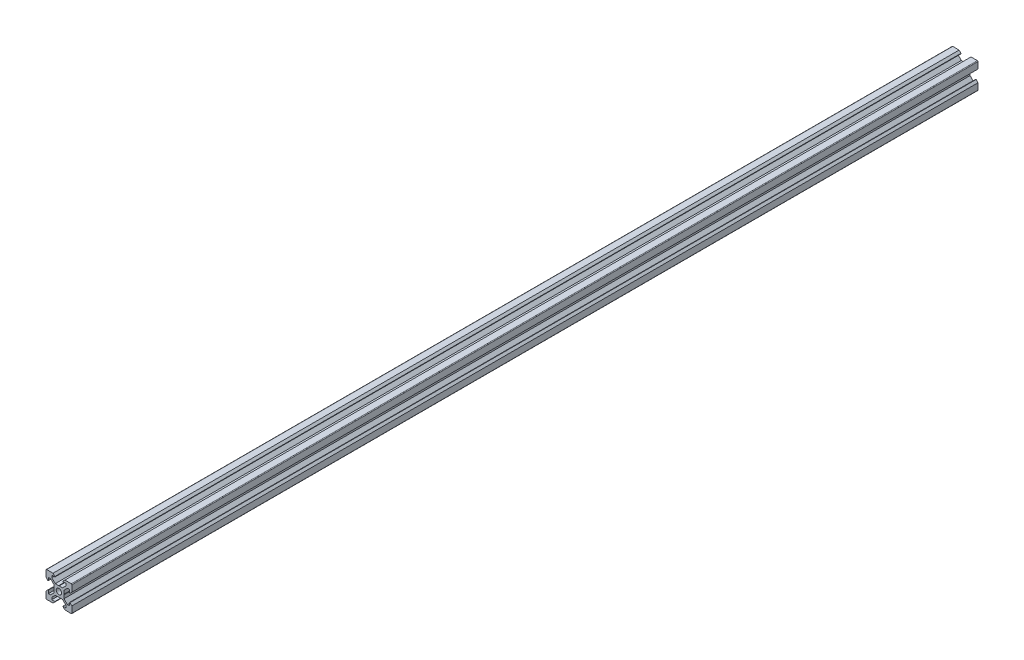
from build123d import *

# Parameters (mm, degrees)
SKETCH1_R           = 2.1
BOSS_EXTRUDE1_DEPTH = 700


with BuildPart() as part:
    # Sketch1 → Boss-Extrude1 (new body)
    with BuildSketch(Plane.XY):
        with BuildLine():
            Line((4.58, -10), (9.5, -10))
            ThreePointArc((9.5, -10), (9.853553391, -9.853553391), (10, -9.5))
            Line((10, -9.5), (10, -4.58))
            Line((10, -4.58), (8.545, -3.125))
            Line((8.545, -3.125), (8.2, -3.125))
            Line((8.2, -3.125), (8.2, -5.5))
            Line((8.2, -5.5), (6.560660172, -5.5))
            Line((6.560660172, -5.5), (3.9, -2.839339828))
            Line((3.9, -2.839339828), (3.9, -0.21))
            Line((3.9, -0.21), (3.69, 0))
            Line((3.69, 0), (3.9, 0.21))
            Line((3.9, 0.21), (3.9, 2.839339828))
            Line((3.9, 2.839339828), (6.560660172, 5.5))
            Line((6.560660172, 5.5), (8.2, 5.5))
            Line((8.2, 5.5), (8.2, 3.125))
            Line((8.2, 3.125), (8.545, 3.125))
            Line((8.545, 3.125), (10, 4.58))
            Line((10, 4.58), (10, 9.5))
            ThreePointArc((10, 9.5), (9.853553391, 9.853553391), (9.5, 10))
            Line((9.5, 10), (4.58, 10))
            Line((4.58, 10), (3.125, 8.545))
            Line((3.125, 8.545), (3.125, 8.2))
            Line((3.125, 8.2), (5.5, 8.2))
            Line((5.5, 8.2), (5.5, 6.560660172))
            Line((5.5, 6.560660172), (2.839339828, 3.9))
            Line((2.839339828, 3.9), (0.21, 3.9))
            Line((0.21, 3.9), (0, 3.69))
            Line((0, 3.69), (-0.21, 3.9))
            Line((-0.21, 3.9), (-2.839339828, 3.9))
            Line((-2.839339828, 3.9), (-5.5, 6.560660172))
            Line((-5.5, 6.560660172), (-5.5, 8.2))
            Line((-5.5, 8.2), (-3.125, 8.2))
            Line((-3.125, 8.2), (-3.125, 8.545))
            Line((-3.125, 8.545), (-4.58, 10))
            Line((-4.58, 10), (-9.5, 10))
            ThreePointArc((-9.5, 10), (-9.853553391, 9.853553391), (-10, 9.5))
            Line((-10, 9.5), (-10, 4.58))
            Line((-10, 4.58), (-8.545, 3.125))
            Line((-8.545, 3.125), (-8.2, 3.125))
            Line((-8.2, 3.125), (-8.2, 5.5))
            Line((-8.2, 5.5), (-6.560660172, 5.5))
            Line((-6.560660172, 5.5), (-3.9, 2.839339828))
            Line((-3.9, 2.839339828), (-3.9, 0.21))
            Line((-3.9, 0.21), (-3.69, 0))
            Line((-3.69, 0), (-3.9, -0.21))
            Line((-3.9, -0.21), (-3.9, -2.839339828))
            Line((-3.9, -2.839339828), (-6.560660172, -5.5))
            Line((-6.560660172, -5.5), (-8.2, -5.5))
            Line((-8.2, -5.5), (-8.2, -3.125))
            Line((-8.2, -3.125), (-8.545, -3.125))
            Line((-8.545, -3.125), (-10, -4.58))
            Line((-10, -4.58), (-10, -9.5))
            ThreePointArc((-10, -9.5), (-9.853553391, -9.853553391), (-9.5, -10))
            Line((-9.5, -10), (-4.58, -10))
            Line((-4.58, -10), (-3.125, -8.545))
            Line((-3.125, -8.545), (-3.125, -8.2))
            Line((-3.125, -8.2), (-5.5, -8.2))
            Line((-5.5, -8.2), (-5.5, -6.560660172))
            Line((-5.5, -6.560660172), (-2.839339828, -3.9))
            Line((-2.839339828, -3.9), (-0.21, -3.9))
            Line((-0.21, -3.9), (0, -3.69))
            Line((0, -3.69), (0.21, -3.9))
            Line((0.21, -3.9), (2.839339828, -3.9))
            Line((2.839339828, -3.9), (5.5, -6.560660172))
            Line((5.5, -6.560660172), (5.5, -8.2))
            Line((5.5, -8.2), (3.125, -8.2))
            Line((3.125, -8.2), (3.125, -8.545))
            Line((3.125, -8.545), (4.58, -10))
        make_face()
        Circle(SKETCH1_R, mode=Mode.SUBTRACT)
    extrude(amount=BOSS_EXTRUDE1_DEPTH)


solid = part.part
